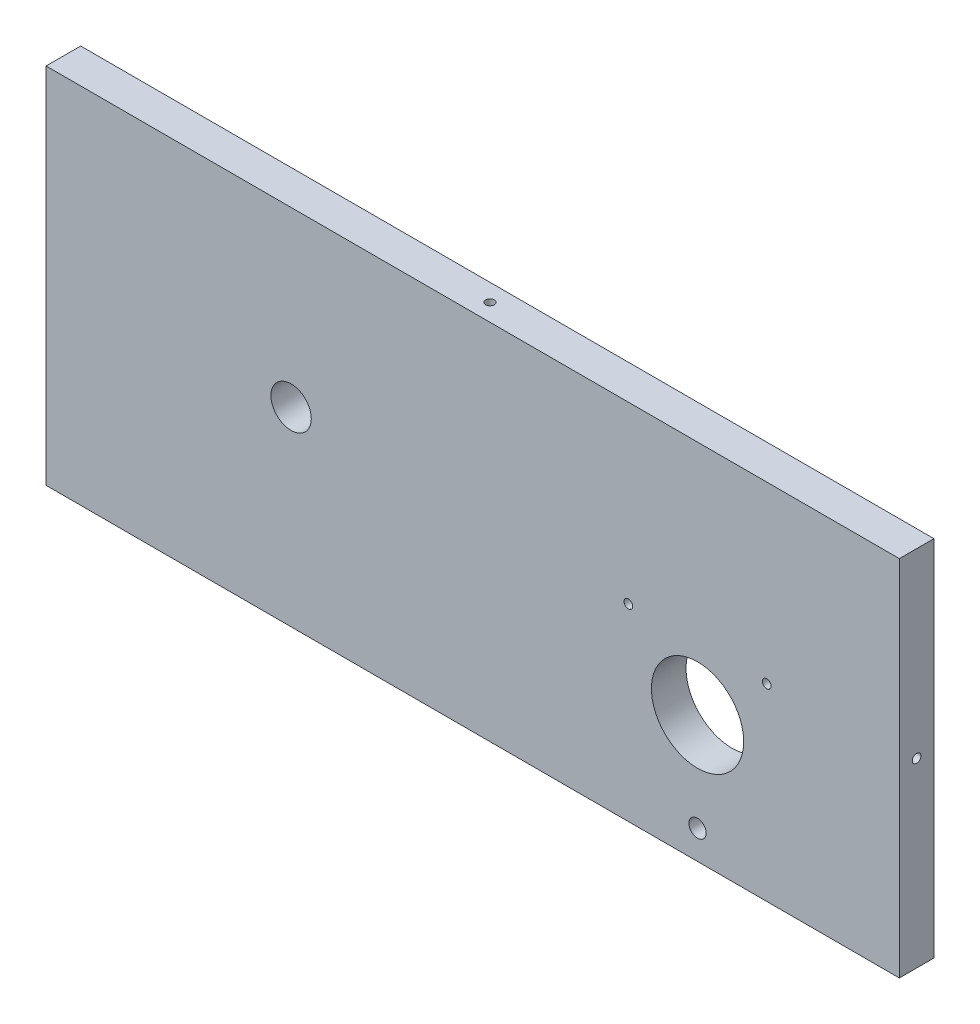
from build123d import *

# Parameters (mm, degrees)
SKETCH1_W           = 296
SKETCH1_H           = 126
SKETCH1_R           = 16
SKETCH1_R_2         = 7
SKETCH1_R_3         = 1.5
SKETCH1_R_4         = 3
BOSS_EXTRUDE1_DEPTH = 12
CUT_EXTRUDE1_START  = 90.297917
SKETCH2_R           = 1.5
CUT_EXTRUDE1_DEPTH  = 20
CUT_EXTRUDE3_START  = 163.485661
SKETCH3_R           = 1.5
CUT_EXTRUDE3_DEPTH  = 20
CUT_EXTRUDE4_START  = -132.514339
SKETCH3_2_R         = 1.5
CUT_EXTRUDE4_DEPTH  = 20
SKETCH4_R           = 3
CUT_EXTRUDE5_DEPTH  = 3
CUT_EXTRUDE5_TAPER  = 45


with BuildPart() as part:
    # Sketch1 → Boss-Extrude1 (new body)
    with BuildSketch(Plane.XY):
        with Locations((15.485661099, 27.29791691)):
            Rectangle(SKETCH1_W, SKETCH1_H)
        with Locations((93.485661099, 8.29791691)):
            Circle(SKETCH1_R, mode=Mode.SUBTRACT)
        with Locations((-47.514338901, 30.29791691)):
            Circle(SKETCH1_R_2, mode=Mode.SUBTRACT)
        with Locations((69.485661099, 29.69791691)):
            Circle(SKETCH1_R_3, mode=Mode.SUBTRACT)
        with Locations((117.485661099, 29.69791691)):
            Circle(SKETCH1_R_3, mode=Mode.SUBTRACT)
        with Locations((93.485661099, -25.70208309)):
            Circle(SKETCH1_R_4, mode=Mode.SUBTRACT)
    extrude(amount=BOSS_EXTRUDE1_DEPTH)

    # Sketch2 → Cut-Extrude1 (cut)
    with BuildSketch(Plane(origin=(0, 0, 0), x_dir=(1, 0, 0), z_dir=(0, 1, 0)).offset(CUT_EXTRUDE1_START)):
        with Locations((15.485661099, -6)):
            Circle(SKETCH2_R)
    extrude(amount=-CUT_EXTRUDE1_DEPTH, mode=Mode.SUBTRACT)

    # Sketch3 → Cut-Extrude3 (cut)
    with BuildSketch(Plane(origin=(0, 0, 0), x_dir=(0, 0, -1), z_dir=(1, 0, 0)).offset(CUT_EXTRUDE3_START)):
        with Locations((-6, 27.29791691)):
            Circle(SKETCH3_R)
    extrude(amount=-CUT_EXTRUDE3_DEPTH, mode=Mode.SUBTRACT)

    # Sketch3_2 → Cut-Extrude4 (cut)
    with BuildSketch(Plane(origin=(0, 0, 0), x_dir=(0, 0, -1), z_dir=(1, 0, 0)).offset(CUT_EXTRUDE4_START)):
        with Locations((-6, 27.29791691)):
            Circle(SKETCH3_2_R)
    extrude(amount=CUT_EXTRUDE4_DEPTH, mode=Mode.SUBTRACT)

    # Sketch4 → Cut-Extrude5 (cut)
    with BuildSketch(Plane.XY):
        with Locations((117.485661099, 29.69791691)):
            Circle(SKETCH4_R)
        with Locations((69.485661099, 29.69791691)):
            Circle(SKETCH4_R)
    extrude(amount=CUT_EXTRUDE5_DEPTH, taper=CUT_EXTRUDE5_TAPER, mode=Mode.SUBTRACT)


solid = part.part
